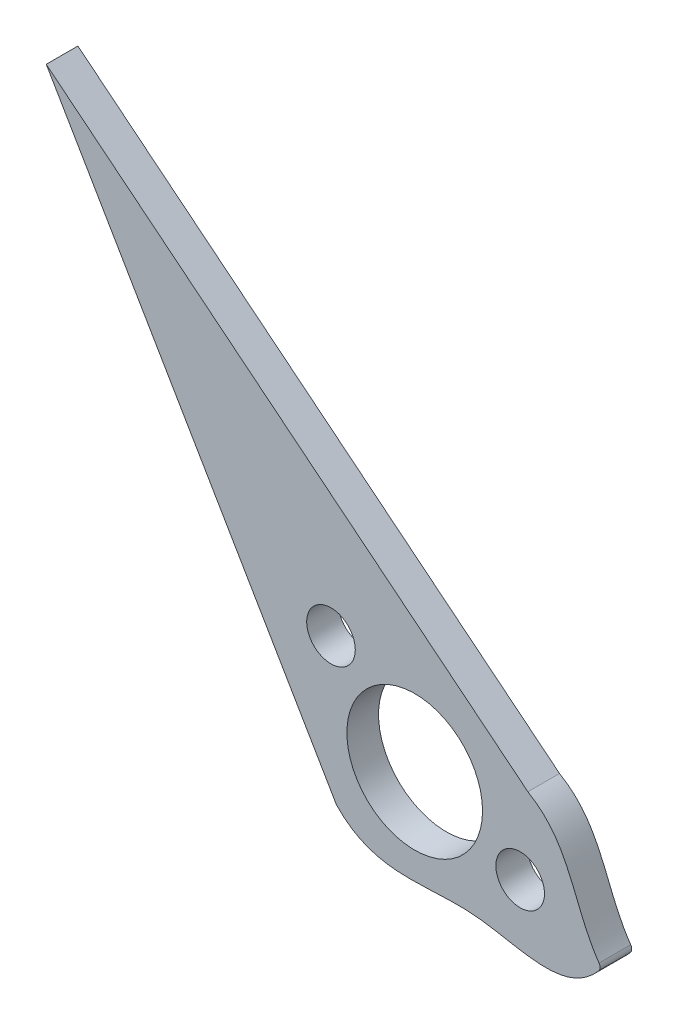
from build123d import *

# Parameters (mm, degrees)
SKETCH1_R           = 6
SKETCH1_R_2         = 2.15
BOSS_EXTRUDE3_DEPTH = 2.8
FILLET2_R           = 0.5


with BuildPart() as part:
    # Sketch1 → Boss-Extrude3 (new body)
    with BuildSketch(Plane.XY):
        with BuildLine():
            Line((-6.914903584, -6.003890728), (-32.597767901, 37.912867577))
            Line((-32.597767901, 37.912867577), (10.012592639, 3.48020667))
            add(Edge.make_bspline(
                [(10.012592639, 3.48020667), (13.976241168, 1.192727745), (14.014521415, -3.518986682), (16.534972158, -6.795729316)],
                knots=[0, 0, 0, 0, 1, 1, 1, 1], degree=3))
            add(Edge.make_bspline(
                [(-6.914903584, -6.003890728), (-3.45265208, -9.610347217), (5.034074198, -6.462522657), (13.416090218, -10.783276778), (16.534972158, -6.795729316)],
                knots=[0, 0, 0, 0, 0.517120054, 1, 1, 1, 1], degree=3))
        make_face()
        Circle(SKETCH1_R, mode=Mode.SUBTRACT)
        with Locations((-7.406949835, 6.718414556)):
            Circle(SKETCH1_R_2, mode=Mode.SUBTRACT)
        with Locations((9.329230051, -3.600759177)):
            Circle(SKETCH1_R_2, mode=Mode.SUBTRACT)
    extrude(amount=BOSS_EXTRUDE3_DEPTH)

    # Fillet2
    fillet2_edges = [part.edges().sort_by_distance(p)[0] for p in [
        (16.534972158, -6.795729316, 1.4),
    ]]
    fillet(fillet2_edges, radius=FILLET2_R)


solid = part.part
